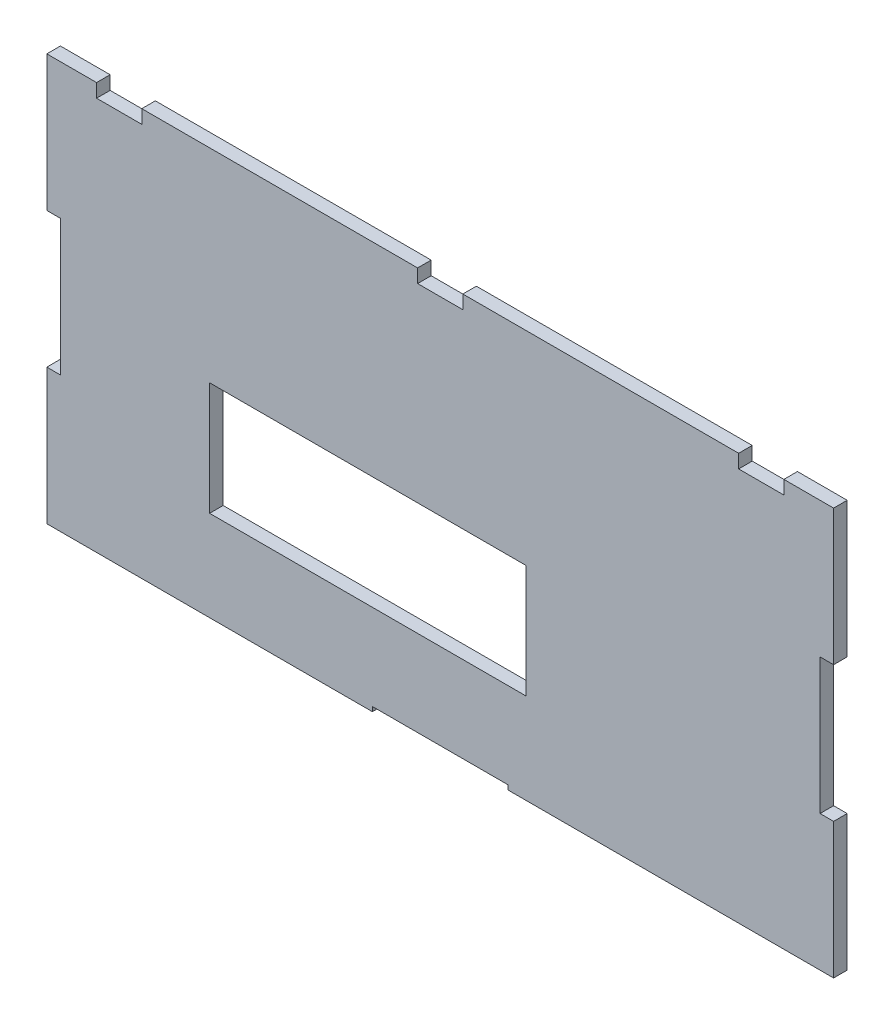
from build123d import *

# Parameters (mm, degrees)
MODEL_W             = 70
MODEL_H             = 25
BOSS_EXTRUDE1_DEPTH = 3


with BuildPart() as part:
    # Model → Boss-Extrude1 (new body)
    with BuildSketch(Plane.XY):
        Polygon((249.402887008, 1.915275896), (249.402887008, -28.084724104), (252.402887008, -28.084724104), (252.402887008, -58.084724104), (180.402887008, -58.084724104), (180.402887008, -57.084724104), (150.402887008, -57.084724104), (150.402887008, -58.084724104), (78.402887008, -58.084724104), (78.402887008, -28.084724104), (81.402887008, -28.084724104), (81.402887008, 1.915275896), (78.402887008, 1.915275896), (78.402887008, 31.915275896), (89.402887008, 31.915275896), (89.402887008, 28.915275896), (99.402887008, 28.915275896), (99.402887008, 31.915275896), (160.402887008, 31.915275896), (160.402887008, 28.915275896), (170.402887008, 28.915275896), (170.402887008, 31.915275896), (231.402887008, 31.915275896), (231.402887008, 28.915275896), (241.402887008, 28.915275896), (241.402887008, 31.915275896), (252.402887008, 31.915275896), (252.402887008, 1.915275896), align=None)
        with Locations((149.402887008, -25.584724104)):
            Rectangle(MODEL_W, MODEL_H, mode=Mode.SUBTRACT)
    extrude(amount=BOSS_EXTRUDE1_DEPTH)


solid = part.part
